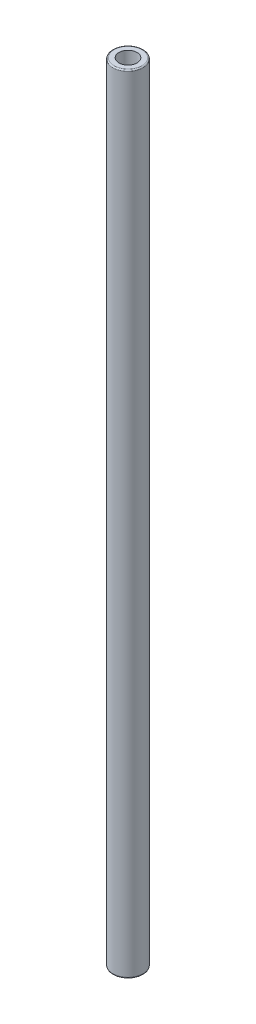
from build123d import *

# Parameters (mm, degrees)
SKETCH5_R      = 2.5
SKETCH5_R_2    = 1.5
MAINBODY_DEPTH = 65
F_0_2MM_R      = 0.2


with BuildPart() as part:
    # Sketch5 → MainBody (new body, symmetric)
    with BuildSketch(Plane(origin=(0, 0, 0), x_dir=(1, 0, 0), z_dir=(0, 1, 0))):
        Circle(SKETCH5_R)
        Circle(SKETCH5_R_2, mode=Mode.SUBTRACT)
    extrude(amount=MAINBODY_DEPTH, both=True)

    # 0.2mm
    f_0_2mm_edges = [part.edges().sort_by_distance(p)[0] for p in [
        (-2.5, -65, 0),
        (-2.5, 65, 0),
    ]]
    fillet(f_0_2mm_edges, radius=F_0_2MM_R)


solid = part.part
